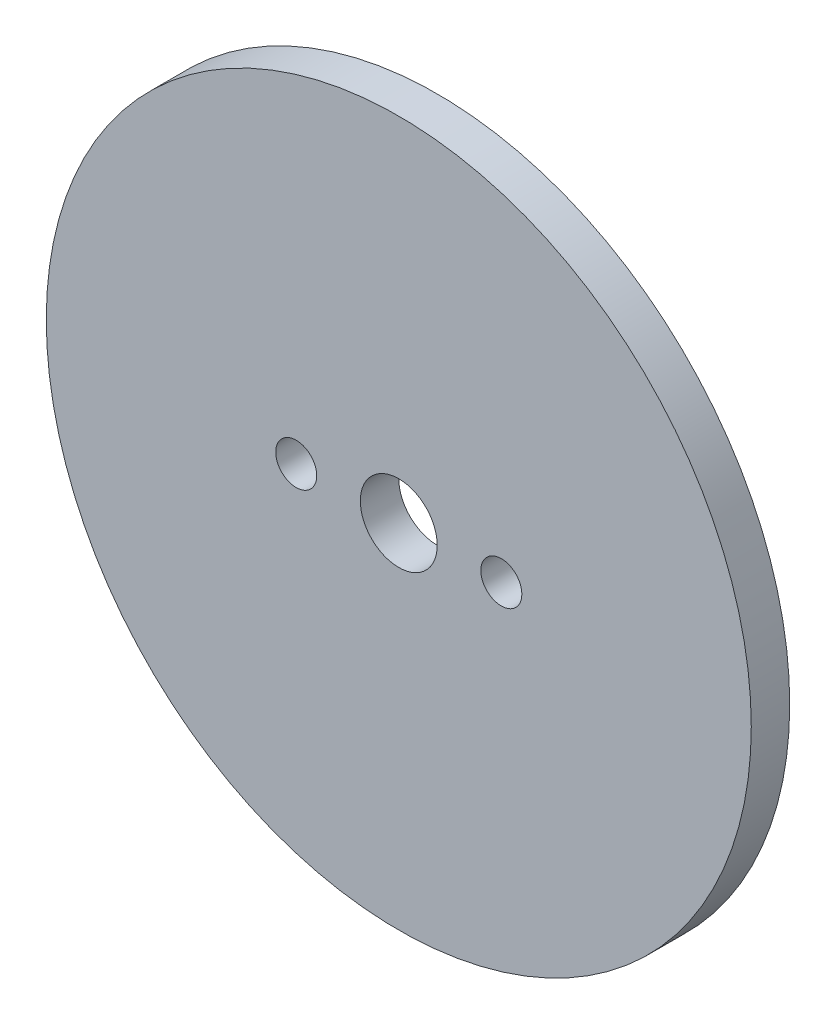
from build123d import *

# Parameters (mm, degrees)
ESBO_O1_R                = 27.5
ESBO_O1_R_2              = 3
ESBO_O1_R_3              = 1.6
RESSALTO_EXTRUS_O1_DEPTH = 1.5


with BuildPart() as part:
    # Esboço1 → Ressalto-extrusão1 (new body, symmetric)
    with BuildSketch(Plane.XY):
        Circle(ESBO_O1_R)
        Circle(ESBO_O1_R_2, mode=Mode.SUBTRACT)
        with Locations((-8, 0)):
            Circle(ESBO_O1_R_3, mode=Mode.SUBTRACT)
        with Locations((8, 0)):
            Circle(ESBO_O1_R_3, mode=Mode.SUBTRACT)
    extrude(amount=RESSALTO_EXTRUS_O1_DEPTH, both=True)


solid = part.part
